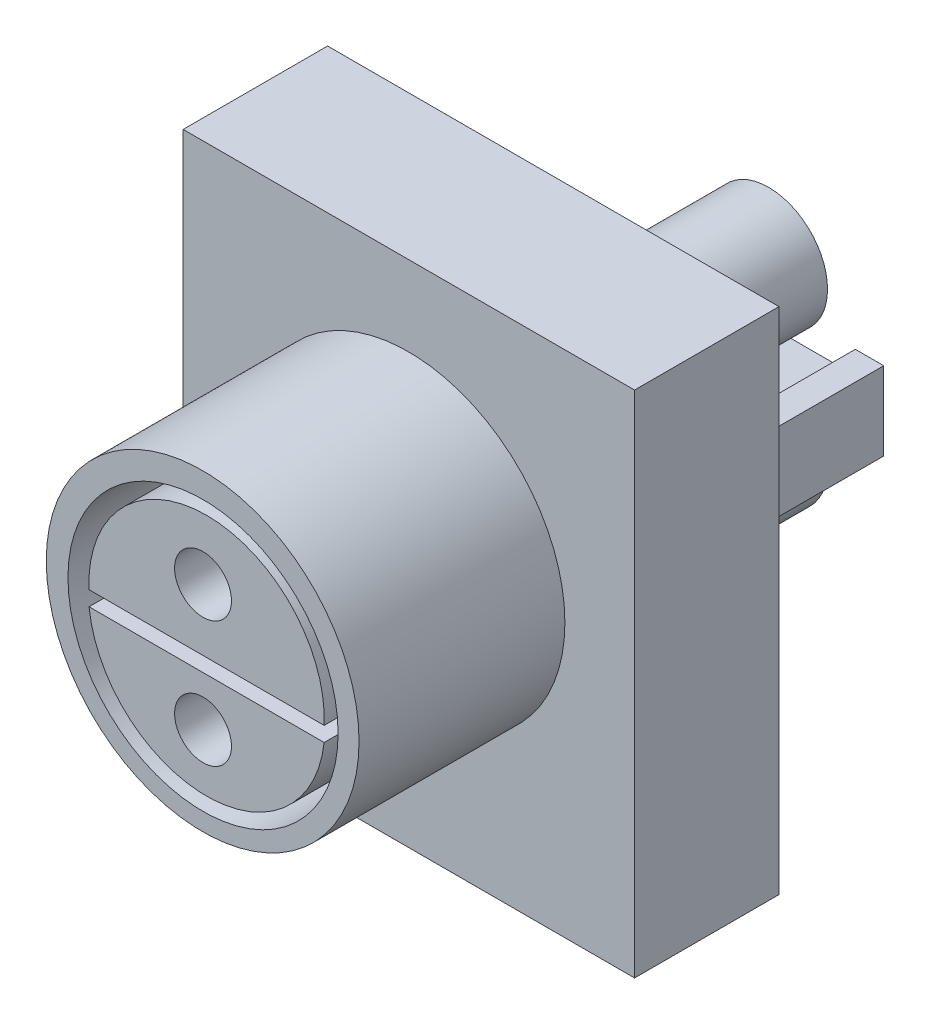
from build123d import *

# Parameters (mm, degrees)
SKETCH1_W           = 31.75
SKETCH1_H           = 35.814
BOSS_EXTRUDE1_DEPTH = 10.16
SKETCH3_R           = 11
BOSS_EXTRUDE2_DEPTH = 14.478
SKETCH4_W           = 16
SKETCH4_H           = 5.5
BOSS_EXTRUDE3_DEPTH = 15.24
SKETCH5_R           = 9.5
CUT_EXTRUDE1_DEPTH  = 8.5
SKETCH6_R           = 2
CUT_EXTRUDE2_DEPTH  = 8.5
SKETCH7_R           = 2
CUT_EXTRUDE3_DEPTH  = 8.5
SKETCH8_W           = 12
SKETCH8_H           = 1.6
CUT_EXTRUDE4_DEPTH  = 15.15
SKETCH10_W          = 12
SKETCH10_H          = 1.6
CUT_EXTRUDE5_DEPTH  = 15.15
SKETCH12_R          = 4.135780917
BOSS_EXTRUDE4_DEPTH = 15.15
SKETCH13_R          = 3
CUT_EXTRUDE6_DEPTH  = 15.15
SKETCH14_R          = 4.135
BOSS_EXTRUDE5_DEPTH = 15.15
SKETCH15_R          = 3
CUT_EXTRUDE7_DEPTH  = 15.15


with BuildPart() as part:
    # Sketch1 → Boss-Extrude1 (new body)
    with BuildSketch(Plane.XY):
        Rectangle(SKETCH1_W, SKETCH1_H)
    extrude(amount=BOSS_EXTRUDE1_DEPTH)

    # Sketch3 → Boss-Extrude2 (add)
    with BuildSketch(Plane.XY.offset(10.16)):
        with Locations((-0.024824202, 1.289107608)):
            Circle(SKETCH3_R)
    extrude(amount=BOSS_EXTRUDE2_DEPTH)

    # Sketch4 → Boss-Extrude3 (add)
    with BuildSketch(Plane(origin=(0, 0, 0), x_dir=(-1, 0, 0), z_dir=(0, 0, -1))):
        Rectangle(SKETCH4_W, SKETCH4_H)
    extrude(amount=BOSS_EXTRUDE3_DEPTH)

    # Sketch5 → Cut-Extrude1 (cut)
    with BuildSketch(Plane.XY.offset(24.638)):
        with Locations((0, 1.039705526)):
            Circle(SKETCH5_R)
        with BuildLine():
            Line((-8.015794219, 0), (8.518877538, 0))
            ThreePointArc((8.518877538, 0), (0.25154166, -7.404071177), (-8.015794219, 0))
        make_face(mode=Mode.SUBTRACT)
        with BuildLine():
            Line((-8.015794219, 1.039705526), (8.518877538, 1.039705526))
            ThreePointArc((8.518877538, 1.039705526), (0.25154166, 9.706845425), (-8.015794219, 1.039705526))
        make_face(mode=Mode.SUBTRACT)
    extrude(amount=-CUT_EXTRUDE1_DEPTH, mode=Mode.SUBTRACT)

    # Sketch6 → Cut-Extrude2 (cut)
    with BuildSketch(Plane.XY.offset(24.638)):
        with Locations((0, 5.366222071)):
            Circle(SKETCH6_R)
    extrude(amount=-CUT_EXTRUDE2_DEPTH, mode=Mode.SUBTRACT)

    # Sketch7 → Cut-Extrude3 (cut)
    with BuildSketch(Plane.XY.offset(24.638)):
        with Locations((0, -3.488044346)):
            Circle(SKETCH7_R)
    extrude(amount=-CUT_EXTRUDE3_DEPTH, mode=Mode.SUBTRACT)

    # Sketch8 → Cut-Extrude4 (cut)
    with BuildSketch(Plane(origin=(0, 0, -15.24), x_dir=(-1, 0, 0), z_dir=(0, 0, -1))):
        with Locations((0, 1.95)):
            Rectangle(SKETCH8_W, SKETCH8_H)
    extrude(amount=-CUT_EXTRUDE4_DEPTH, mode=Mode.SUBTRACT)

    # Sketch10 → Cut-Extrude5 (cut)
    with BuildSketch(Plane(origin=(0, 0, -15.24), x_dir=(-1, 0, 0), z_dir=(0, 0, -1))):
        with Locations((0, -1.95)):
            Rectangle(SKETCH10_W, SKETCH10_H)
    extrude(amount=-CUT_EXTRUDE5_DEPTH, mode=Mode.SUBTRACT)

    # Sketch12 → Boss-Extrude4 (add)
    with BuildSketch(Plane(origin=(0, 0, 0), x_dir=(-1, 0, 0), z_dir=(0, 0, -1))):
        with Locations((0, 5.523554626)):
            Circle(SKETCH12_R)
    extrude(amount=BOSS_EXTRUDE4_DEPTH)

    # Sketch13 → Cut-Extrude6 (cut)
    with BuildSketch(Plane(origin=(0, 0, -15.15), x_dir=(-1, 0, 0), z_dir=(0, 0, -1))):
        with Locations((0, 5.628086678)):
            Circle(SKETCH13_R)
    extrude(amount=-CUT_EXTRUDE6_DEPTH, mode=Mode.SUBTRACT)

    # Sketch14 → Boss-Extrude5 (add)
    with BuildSketch(Plane(origin=(0, 0, 0), x_dir=(-1, 0, 0), z_dir=(0, 0, -1))):
        with Locations((0, -5.366222071)):
            Circle(SKETCH14_R)
    extrude(amount=BOSS_EXTRUDE5_DEPTH)

    # Sketch15 → Cut-Extrude7 (cut)
    with BuildSketch(Plane(origin=(0, 0, -15.15), x_dir=(-1, 0, 0), z_dir=(0, 0, -1))):
        with Locations((0, -5.366222071)):
            Circle(SKETCH15_R)
    extrude(amount=-CUT_EXTRUDE7_DEPTH, mode=Mode.SUBTRACT)


solid = part.part
